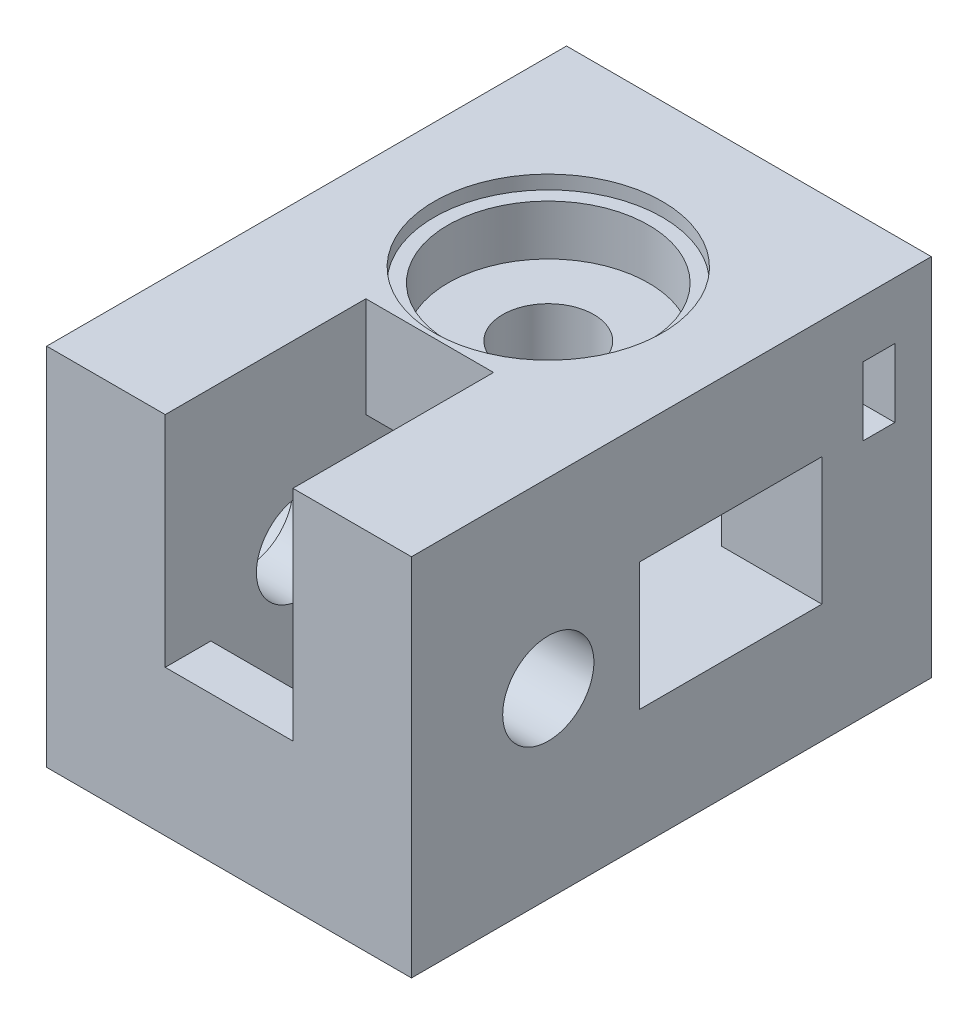
from build123d import *

# Parameters (mm, degrees)
ESQUISSE1_W              = 40
ESQUISSE1_H              = 40
BOSS_EXTRU_1_DEPTH       = 50
ESQUISSE2_R              = 5
ENL_V_MAT_EXTRU_1_DEPTH  = 41
ESQUISSE3_R              = 5
ENL_V_MAT_EXTRU_2_DEPTH  = 41
ESQUISSE4_W              = 22
ESQUISSE4_H              = 14
ENL_V_MAT_EXTRU_3_DEPTH  = 29
ESQUISSE5_W              = 14
ESQUISSE5_H              = 20
ENL_V_MAT_EXTRU_4_DEPTH  = 29
ESQUISSE6_W              = 20
ESQUISSE6_H              = 14
ENL_V_MAT_EXTRU_5_DEPTH  = 24
ESQUISSE7_W              = 14
ESQUISSE7_H              = 22
ENL_V_MAT_EXTRU_6_DEPTH  = 24
ESQUISSE10_R             = 11
ENL_V_MAT_EXTRU_9_DEPTH  = 7
ESQUISSE11_R             = 12.5
ENL_V_MAT_EXTRU_10_DEPTH = 1.5
ESQUISSE14_R             = 11
ENL_V_MAT_EXTRU_11_DEPTH = 7
ESQUISSE15_R             = 12.5
ENL_V_MAT_EXTRU_12_DEPTH = 1.5
ESQUISSE16_W             = 40
ESQUISSE16_H             = 40
BOSS_EXTRU_2_DEPTH       = 7
ESQUISSE17_R             = 2.25
ENL_V_MAT_EXTRU_13_DEPTH = 15
ESQUISSE18_W             = 3.5
ESQUISSE18_H             = 7.5
ENL_V_MAT_EXTRU_14_DEPTH = 12
ESQUISSE19_W             = 7.5
ESQUISSE19_H             = 3.5
ENL_V_MAT_EXTRU_15_DEPTH = 12


with BuildPart() as part:
    # Esquisse1 → Boss.-Extru.1 (new body)
    with BuildSketch(Plane.XY):
        with Locations((-20, 20)):
            Rectangle(ESQUISSE1_W, ESQUISSE1_H)
    extrude(amount=BOSS_EXTRU_1_DEPTH)

    # Esquisse2 → Enlèv. mat.-Extru.1 (cut, through all)
    with BuildSketch(Plane(origin=(0, 40, 0), x_dir=(1, 0, 0), z_dir=(0, 1, 0))):
        with Locations(Location((-20, -15, 0), (0, 0, 270))):  # turned: the seam where the file's is
            Circle(ESQUISSE2_R)
    extrude(amount=-ENL_V_MAT_EXTRU_1_DEPTH, mode=Mode.SUBTRACT)

    # Esquisse3 → Enlèv. mat.-Extru.2 (cut, through all)
    with BuildSketch(Plane.ZY.offset(40)):
        with Locations((35, 20)):
            Circle(ESQUISSE3_R)
    extrude(amount=-ENL_V_MAT_EXTRU_2_DEPTH, mode=Mode.SUBTRACT)

    # Esquisse4 → Enlèv. mat.-Extru.3 (cut)
    with BuildSketch(Plane.ZY.offset(40)):
        with Locations((11, 20)):
            Rectangle(ESQUISSE4_W, ESQUISSE4_H)
    extrude(amount=-ENL_V_MAT_EXTRU_3_DEPTH, mode=Mode.SUBTRACT)

    # Esquisse5 → Enlèv. mat.-Extru.4 (cut)
    with BuildSketch(Plane.XZ):
        with Locations((-20, 35)):
            Rectangle(ESQUISSE5_W, ESQUISSE5_H)
    extrude(amount=-ENL_V_MAT_EXTRU_4_DEPTH, mode=Mode.SUBTRACT)

    # Esquisse6 → Enlèv. mat.-Extru.5 (cut)
    with BuildSketch(Plane(origin=(0, 0, 0), x_dir=(0, 0, -1), z_dir=(1, 0, 0))):
        with Locations((-15, 20)):
            Rectangle(ESQUISSE6_W, ESQUISSE6_H)
    extrude(amount=-ENL_V_MAT_EXTRU_5_DEPTH, mode=Mode.SUBTRACT)

    # Esquisse7 → Enlèv. mat.-Extru.6 (cut)
    with BuildSketch(Plane(origin=(0, 40, 0), x_dir=(1, 0, 0), z_dir=(0, 1, 0))):
        with Locations((-20, -39)):
            Rectangle(ESQUISSE7_W, ESQUISSE7_H)
    extrude(amount=-ENL_V_MAT_EXTRU_6_DEPTH, mode=Mode.SUBTRACT)

    # Esquisse10 → Enlèv. mat.-Extru.9 (cut)
    with BuildSketch(Plane(origin=(0, 40, 0), x_dir=(1, 0, 0), z_dir=(0, 1, 0))):
        with Locations(Location((-20, -15, 0), (0, 0, 270))):  # turned: the seam where the file's is
            Circle(ESQUISSE10_R)
    extrude(amount=-ENL_V_MAT_EXTRU_9_DEPTH, mode=Mode.SUBTRACT)

    # Esquisse11 → Enlèv. mat.-Extru.10 (cut)
    with BuildSketch(Plane(origin=(0, 40, 0), x_dir=(1, 0, 0), z_dir=(0, 1, 0))):
        with Locations(Location((-20, -15, 0), (0, 0, 270))):  # turned: the seam where the file's is
            Circle(ESQUISSE11_R)
    extrude(amount=-ENL_V_MAT_EXTRU_10_DEPTH, mode=Mode.SUBTRACT)

    # Esquisse14 → Enlèv. mat.-Extru.11 (cut)
    with BuildSketch(Plane.ZY.offset(40)):
        with Locations((35, 20)):
            Circle(ESQUISSE14_R)
    extrude(amount=-ENL_V_MAT_EXTRU_11_DEPTH, mode=Mode.SUBTRACT)

    # Esquisse15 → Enlèv. mat.-Extru.12 (cut)
    with BuildSketch(Plane.ZY.offset(40)):
        with Locations((35, 20)):
            Circle(ESQUISSE15_R)
    extrude(amount=-ENL_V_MAT_EXTRU_12_DEPTH, mode=Mode.SUBTRACT)

    # Esquisse16 → Boss.-Extru.2 (add)
    with BuildSketch(Plane(origin=(0, 0, 0), x_dir=(-1, 0, 0), z_dir=(0, 0, -1))):
        with Locations((20, 20)):
            Rectangle(ESQUISSE16_W, ESQUISSE16_H)
    extrude(amount=BOSS_EXTRU_2_DEPTH)

    # Esquisse17 → Enlèv. mat.-Extru.13 (cut)
    with BuildSketch(Plane(origin=(0, 0, -7), x_dir=(-1, 0, 0), z_dir=(0, 0, -1))):
        with Locations((7.5, 30)):
            Circle(ESQUISSE17_R)
        with Locations((30, 7.5)):
            Circle(ESQUISSE17_R)
    extrude(amount=-ENL_V_MAT_EXTRU_13_DEPTH, mode=Mode.SUBTRACT)

    # Esquisse18 → Enlèv. mat.-Extru.14 (cut)
    with BuildSketch(Plane(origin=(0, 0, 0), x_dir=(0, 0, -1), z_dir=(1, 0, 0))):
        with Locations((1.25, 30)):
            Rectangle(ESQUISSE18_W, ESQUISSE18_H)
    extrude(amount=-ENL_V_MAT_EXTRU_14_DEPTH, mode=Mode.SUBTRACT)

    # Esquisse19 → Enlèv. mat.-Extru.15 (cut)
    with BuildSketch(Plane.XZ):
        with Locations((-30, -1.25)):
            Rectangle(ESQUISSE19_W, ESQUISSE19_H)
    extrude(amount=-ENL_V_MAT_EXTRU_15_DEPTH, mode=Mode.SUBTRACT)


solid = part.part
